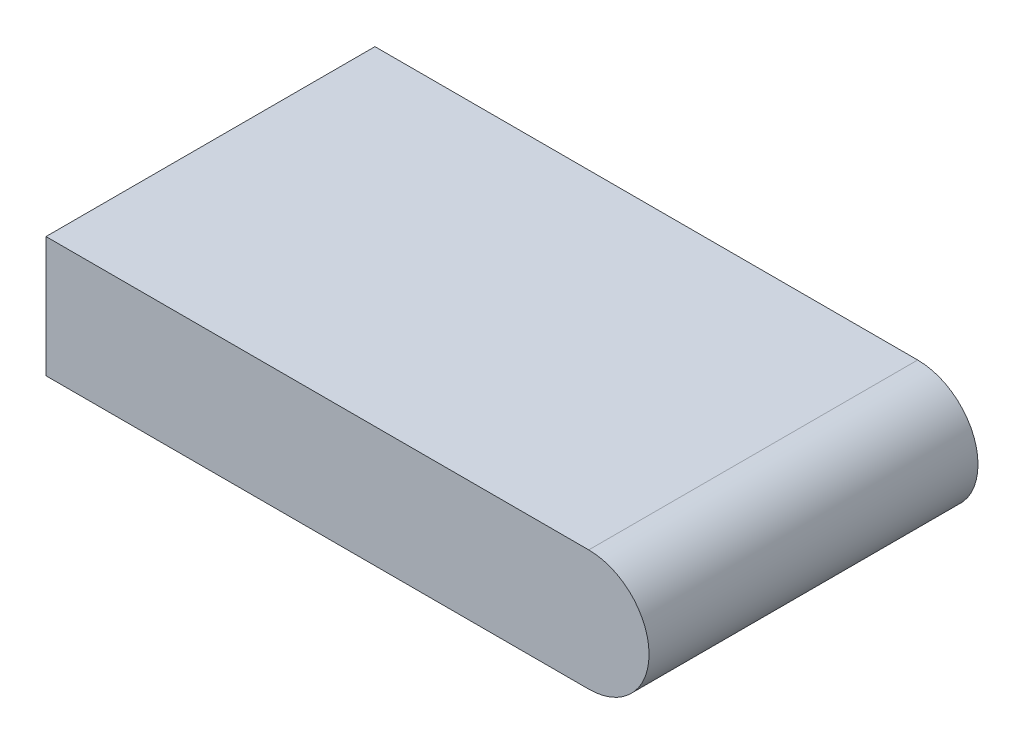
from build123d import *

# Parameters (mm, degrees)
SKETCH2_W           = 49.5
SKETCH2_H           = 30
BOSS_EXTRUDE1_DEPTH = 11
SKETCH4_R           = 5.5
BOSS_EXTRUDE2_DEPTH = 30


with BuildPart() as part:
    # Sketch2 → Boss-Extrude1 (new body)
    with BuildSketch(Plane(origin=(0, 0, 0), x_dir=(1, 0, 0), z_dir=(0, 1, 0))):
        with Locations((24.75, 15)):
            Rectangle(SKETCH2_W, SKETCH2_H)
    extrude(amount=BOSS_EXTRUDE1_DEPTH)

    # Sketch4 → Boss-Extrude2 (add)
    with BuildSketch(Plane(origin=(0, 0, -30), x_dir=(-1, 0, 0), z_dir=(0, 0, -1))):
        with Locations((-49.5, 5.5)):
            Circle(SKETCH4_R)
    extrude(amount=-BOSS_EXTRUDE2_DEPTH)


solid = part.part
